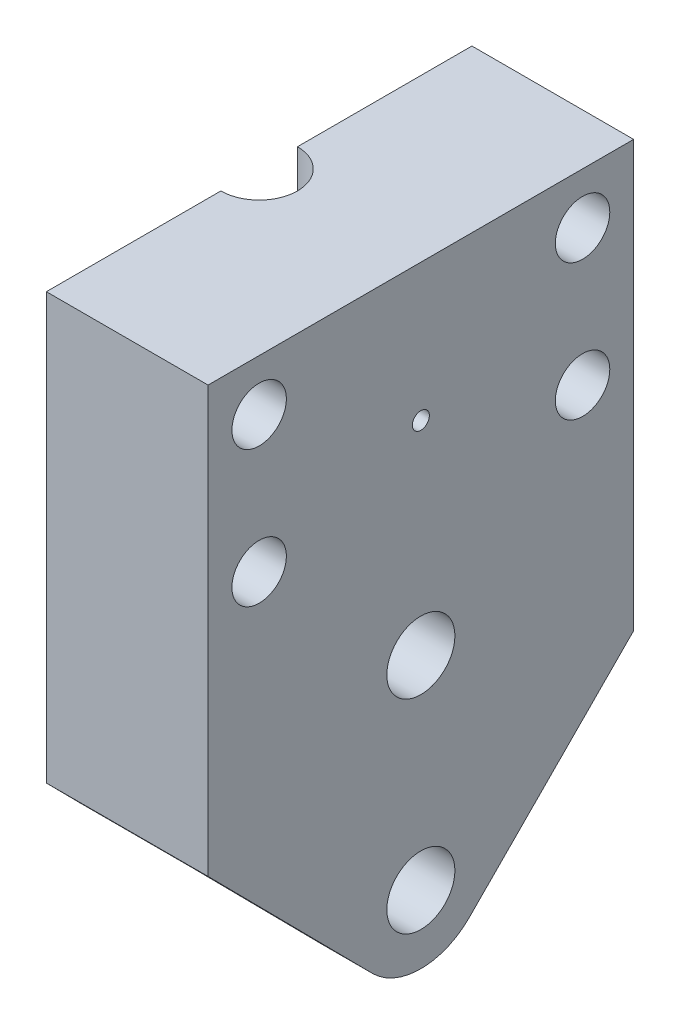
from build123d import *

# Parameters (mm, degrees)
SKETCH1_R           = 2
SKETCH1_R_2         = 0.5
BOSS_EXTRUDE1_DEPTH = 9.5
SKETCH1_3_R         = 2
SKETCH1_3_R_2       = 0.5
CUT_EXTRUDE1_DEPTH  = 6.5
BOSS_EXTRUDE2_DEPTH = 3
CUT_EXTRUDE2_START  = 20
SKETCH3_R           = 2.25
CUT_EXTRUDE2_DEPTH  = 6
SKETCH5_R           = 1.6
CUT_EXTRUDE3_DEPTH  = 10


with BuildPart() as part:
    # Sketch1 → Boss-Extrude1 (new body)
    with BuildSketch(Plane(origin=(0, 0, 0), x_dir=(0, 0, -1), z_dir=(1, 0, 0))):
        with BuildLine():
            Line((2.814717913, -14.792070209), (10.42585747, -7.09701164))
            ThreePointArc((10.42585747, -7.09701164), (9.72468907, -5.811561885), (8.865865393, -4.625627615))
            ThreePointArc((8.865865393, -4.625627615), (9.731180291, 2.303069722), (5.85199823, 8.108891213))
            ThreePointArc((5.85199823, 8.108891213), (0, 18.95), (-5.85199823, 8.108891213))
            ThreePointArc((-5.85199823, 8.108891213), (-9.731180291, 2.303069722), (-8.865865393, -4.625627615))
            ThreePointArc((-8.865865393, -4.625627615), (-9.72468907, -5.811561885), (-10.42585747, -7.09701164))
            Line((-10.42585747, -7.09701164), (-2.814717913, -14.792070209))
            ThreePointArc((-2.814717913, -14.792070209), (0, -15.95), (2.814717913, -14.792070209))
        make_face()
        with Locations((0, -11.95)):
            Circle(SKETCH1_R, mode=Mode.SUBTRACT)
        Circle(SKETCH1_R, mode=Mode.SUBTRACT)
        with Locations((0, 11.95)):
            Circle(SKETCH1_R_2, mode=Mode.SUBTRACT)
        with BuildLine():
            Line((10.42585747, -7.09701164), (12.5, -5))
            Line((12.5, -5), (12.5, 20))
            Line((12.5, 20), (-12.5, 20))
            Line((-12.5, 20), (-12.5, -5))
            Line((-12.5, -5), (-10.42585747, -7.09701164))
            ThreePointArc((-10.42585747, -7.09701164), (-9.72468907, -5.811561885), (-8.865865393, -4.625627615))
            ThreePointArc((-8.865865393, -4.625627615), (-9.731180291, 2.303069722), (-5.85199823, 8.108891213))
            ThreePointArc((-5.85199823, 8.108891213), (0, 18.95), (5.85199823, 8.108891213))
            ThreePointArc((5.85199823, 8.108891213), (9.731180291, 2.303069722), (8.865865393, -4.625627615))
            ThreePointArc((8.865865393, -4.625627615), (9.72468907, -5.811561885), (10.42585747, -7.09701164))
        make_face()
    extrude(amount=BOSS_EXTRUDE1_DEPTH)

    # Sketch1_3 → Cut-Extrude1 (cut)
    with BuildSketch(Plane(origin=(0, 0, 0), x_dir=(0, 0, -1), z_dir=(1, 0, 0))):
        with BuildLine():
            Line((2.814717913, -14.792070209), (10.42585747, -7.09701164))
            ThreePointArc((10.42585747, -7.09701164), (9.72468907, -5.811561885), (8.865865393, -4.625627615))
            ThreePointArc((8.865865393, -4.625627615), (9.731180291, 2.303069722), (5.85199823, 8.108891213))
            ThreePointArc((5.85199823, 8.108891213), (0, 18.95), (-5.85199823, 8.108891213))
            ThreePointArc((-5.85199823, 8.108891213), (-9.731180291, 2.303069722), (-8.865865393, -4.625627615))
            ThreePointArc((-8.865865393, -4.625627615), (-9.72468907, -5.811561885), (-10.42585747, -7.09701164))
            Line((-10.42585747, -7.09701164), (-2.814717913, -14.792070209))
            ThreePointArc((-2.814717913, -14.792070209), (0, -15.95), (2.814717913, -14.792070209))
        make_face()
        with Locations((0, -11.95)):
            Circle(SKETCH1_3_R, mode=Mode.SUBTRACT)
        Circle(SKETCH1_3_R, mode=Mode.SUBTRACT)
        with Locations((0, 11.95)):
            Circle(SKETCH1_3_R_2, mode=Mode.SUBTRACT)
    extrude(amount=CUT_EXTRUDE1_DEPTH, mode=Mode.SUBTRACT)

    # Sketch4 → Boss-Extrude2 (add)
    with BuildSketch(Plane(origin=(0, 0, 0), x_dir=(0, 0, -1), z_dir=(1, 0, 0))):
        with BuildLine():
            Line((4.898979486, 16.95), (-4.898979486, 16.95))
            ThreePointArc((-4.898979486, 16.95), (0, 18.95), (4.898979486, 16.95))
        make_face()
    extrude(amount=BOSS_EXTRUDE2_DEPTH)

    # Sketch3 → Cut-Extrude2 (cut)
    with BuildSketch(Plane(origin=(0, 0, 0), x_dir=(1, 0, 0), z_dir=(0, 1, 0)).offset(CUT_EXTRUDE2_START)):
        Circle(SKETCH3_R)
    extrude(amount=-CUT_EXTRUDE2_DEPTH, mode=Mode.SUBTRACT)

    # Sketch5 → Cut-Extrude3 (cut)
    with BuildSketch(Plane(origin=(0, 0, 0), x_dir=(0, 0, -1), z_dir=(1, 0, 0))):
        with Locations((9.5, 9)):
            Circle(SKETCH5_R)
        with Locations((-9.5, 9)):
            Circle(SKETCH5_R)
        with Locations((-9.5, 17)):
            Circle(SKETCH5_R)
        with Locations((9.5, 17)):
            Circle(SKETCH5_R)
    extrude(amount=CUT_EXTRUDE3_DEPTH, mode=Mode.SUBTRACT)


solid = part.part
